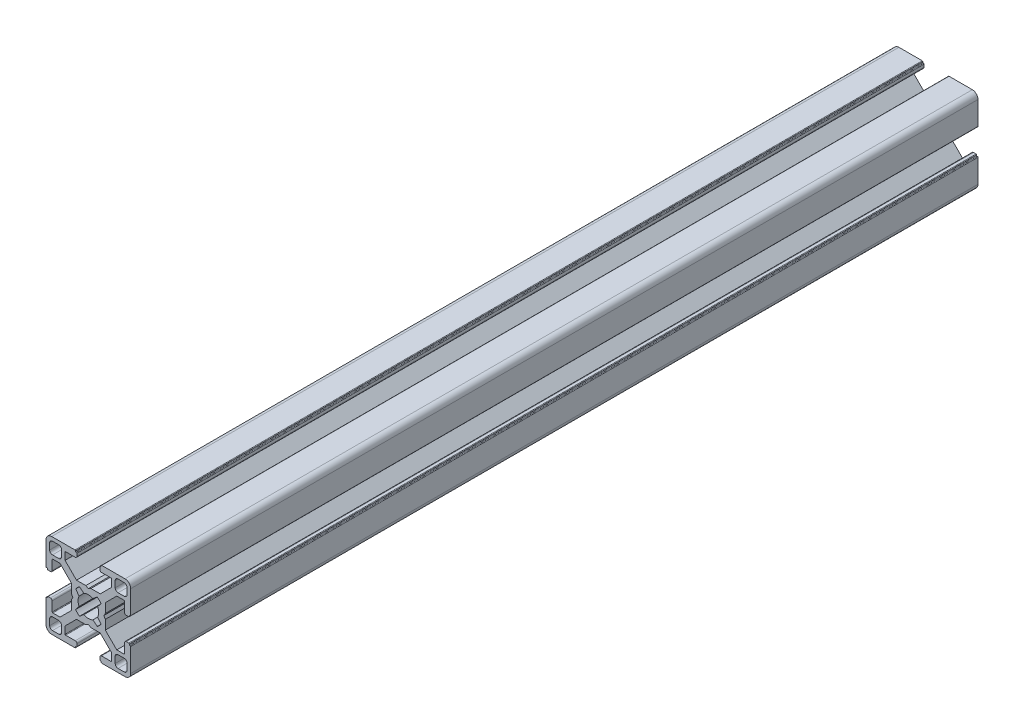
from build123d import *

# Parameters (mm, degrees)
BASE_EXTRUDE_DEPTH = 300


with BuildPart() as part:
    # Sketch1 → Base-Extrude (new body)
    with BuildSketch(Plane.XY):
        with BuildLine():
            Line((6.00446543, 0.899999619), (5.484852164, 0))
            Line((5.484852164, 0), (6.00446543, -0.899999619))
            Line((6.00446543, -0.899999619), (6.00446543, -4.204465866))
            Line((6.00446543, -4.204465866), (10.049999564, -8.25))
            Line((10.049999564, -8.25), (12.59999928, -8.25))
            ThreePointArc((12.59999928, -8.25), (12.741420837, -8.191421273), (12.799999564, -8.049999716))
            Line((12.799999564, -8.049999716), (12.799999564, -4.649999613))
            ThreePointArc((12.799999564, -4.649999613), (12.975735606, -4.225735278), (13.39999994, -4.049999237))
            Line((13.39999994, -4.049999237), (14.300000043, -4.049999237))
            ThreePointArc((14.300000043, -4.049999237), (14.4414216, -4.108577964), (14.500000327, -4.249999521))
            Line((14.500000327, -4.249999521), (14.500000327, -4.349998953))
            ThreePointArc((14.500000327, -4.349998953), (14.558579054, -4.49142051), (14.700000611, -4.549999237))
            Line((14.700000611, -4.549999237), (14.799999716, -4.549999237))
            ThreePointArc((14.799999716, -4.549999237), (14.941421273, -4.608577964), (15, -4.749999521))
            Line((15, -4.749999521), (15, -13.000000346))
            ThreePointArc((15, -13.000000346), (14.414213664, -14.414213664), (13.000000346, -15))
            Line((13.000000346, -15), (4.749999945, -15))
            ThreePointArc((4.749999945, -15), (4.60857832, -14.941421245), (4.549999564, -14.799999619))
            Line((4.549999564, -14.799999619), (4.549999564, -14.69999942))
            ThreePointArc((4.549999564, -14.69999942), (4.49142109, -14.558578474), (4.350000144, -14.5))
            Line((4.350000144, -14.5), (4.250000374, -14.5))
            ThreePointArc((4.250000374, -14.5), (4.108578753, -14.441421247), (4.05, -14.299999626))
            Line((4.05, -14.299999626), (4.05, -13.399999434))
            ThreePointArc((4.05, -13.399999434), (4.225735989, -12.975735226), (4.650000197, -12.799999237))
            Line((4.650000197, -12.799999237), (8.049999924, -12.799999237))
            ThreePointArc((8.049999924, -12.799999237), (8.191421565, -12.741420475), (8.250000327, -12.599998834))
            Line((8.250000327, -12.599998834), (8.250000327, -10.049999237))
            Line((8.250000327, -10.049999237), (4.204466193, -6))
            Line((4.204466193, -6), (0.899999946, -6))
            Line((0.899999946, -6), (0, -5.484851837))
            Line((0, -5.484851837), (-0.899999946, -6))
            Line((-0.899999946, -6), (-4.204466193, -6))
            Line((-4.204466193, -6), (-8.250000327, -10.049999237))
            Line((-8.250000327, -10.049999237), (-8.250000327, -12.599998834))
            ThreePointArc((-8.250000327, -12.599998834), (-8.191421565, -12.741420475), (-8.049999924, -12.799999237))
            Line((-8.049999924, -12.799999237), (-4.650000197, -12.799999237))
            ThreePointArc((-4.650000197, -12.799999237), (-4.225735989, -12.975735226), (-4.05, -13.399999434))
            Line((-4.05, -13.399999434), (-4.05, -14.299999626))
            ThreePointArc((-4.05, -14.299999626), (-4.108578753, -14.441421247), (-4.250000374, -14.5))
            Line((-4.250000374, -14.5), (-4.350000144, -14.5))
            ThreePointArc((-4.350000144, -14.5), (-4.49142109, -14.558578474), (-4.549999564, -14.69999942))
            Line((-4.549999564, -14.69999942), (-4.549999564, -14.799999619))
            ThreePointArc((-4.549999564, -14.799999619), (-4.60857832, -14.941421245), (-4.749999945, -15))
            Line((-4.749999945, -15), (-13.000000346, -15))
            ThreePointArc((-13.000000346, -15), (-14.414213664, -14.414213664), (-15, -13.000000346))
            Line((-15, -13.000000346), (-15, -4.749999521))
            ThreePointArc((-15, -4.749999521), (-14.941421273, -4.608577964), (-14.799999716, -4.549999237))
            Line((-14.799999716, -4.549999237), (-14.700000611, -4.549999237))
            ThreePointArc((-14.700000611, -4.549999237), (-14.558579054, -4.49142051), (-14.500000327, -4.349998953))
            Line((-14.500000327, -4.349998953), (-14.500000327, -4.249999521))
            ThreePointArc((-14.500000327, -4.249999521), (-14.4414216, -4.108577964), (-14.300000043, -4.049999237))
            Line((-14.300000043, -4.049999237), (-13.39999994, -4.049999237))
            ThreePointArc((-13.39999994, -4.049999237), (-12.975735606, -4.225735278), (-12.799999564, -4.649999613))
            Line((-12.799999564, -4.649999613), (-12.799999564, -8.049999716))
            ThreePointArc((-12.799999564, -8.049999716), (-12.741420837, -8.191421273), (-12.59999928, -8.25))
            Line((-12.59999928, -8.25), (-10.049999564, -8.25))
            Line((-10.049999564, -8.25), (-6.00446543, -4.204465866))
            Line((-6.00446543, -4.204465866), (-6.00446543, -0.899999619))
            Line((-6.00446543, -0.899999619), (-5.484852164, 0))
            Line((-5.484852164, 0), (-6.00446543, 0.899999619))
            Line((-6.00446543, 0.899999619), (-6.00446543, 4.204465866))
            Line((-6.00446543, 4.204465866), (-10.049999564, 8.25))
            Line((-10.049999564, 8.25), (-12.59999928, 8.25))
            ThreePointArc((-12.59999928, 8.25), (-12.741420837, 8.191421273), (-12.799999564, 8.049999716))
            Line((-12.799999564, 8.049999716), (-12.799999564, 4.649999613))
            ThreePointArc((-12.799999564, 4.649999613), (-12.975735606, 4.225735278), (-13.39999994, 4.049999237))
            Line((-13.39999994, 4.049999237), (-14.300000043, 4.049999237))
            ThreePointArc((-14.300000043, 4.049999237), (-14.4414216, 4.108577964), (-14.500000327, 4.249999521))
            Line((-14.500000327, 4.249999521), (-14.500000327, 4.349998953))
            ThreePointArc((-14.500000327, 4.349998953), (-14.558579054, 4.49142051), (-14.700000611, 4.549999237))
            Line((-14.700000611, 4.549999237), (-14.799999716, 4.549999237))
            ThreePointArc((-14.799999716, 4.549999237), (-14.941421273, 4.608577964), (-15, 4.749999521))
            Line((-15, 4.749999521), (-15, 13.000000346))
            ThreePointArc((-15, 13.000000346), (-14.414213664, 14.414213664), (-13.000000346, 15))
            Line((-13.000000346, 15), (-4.749999945, 15))
            ThreePointArc((-4.749999945, 15), (-4.60857832, 14.941421245), (-4.549999564, 14.799999619))
            Line((-4.549999564, 14.799999619), (-4.549999564, 14.69999942))
            ThreePointArc((-4.549999564, 14.69999942), (-4.49142109, 14.558578474), (-4.350000144, 14.5))
            Line((-4.350000144, 14.5), (-4.250000374, 14.5))
            ThreePointArc((-4.250000374, 14.5), (-4.108578753, 14.441421247), (-4.05, 14.299999626))
            Line((-4.05, 14.299999626), (-4.05, 13.399999434))
            ThreePointArc((-4.05, 13.399999434), (-4.225735989, 12.975735226), (-4.650000197, 12.799999237))
            Line((-4.650000197, 12.799999237), (-8.049999924, 12.799999237))
            ThreePointArc((-8.049999924, 12.799999237), (-8.191421565, 12.741420475), (-8.250000327, 12.599998834))
            Line((-8.250000327, 12.599998834), (-8.250000327, 10.049999237))
            Line((-8.250000327, 10.049999237), (-4.204466193, 6))
            Line((-4.204466193, 6), (-0.899999946, 6))
            Line((-0.899999946, 6), (0, 5.484851837))
            Line((0, 5.484851837), (0.899999946, 6))
            Line((0.899999946, 6), (4.204466193, 6))
            Line((4.204466193, 6), (8.250000327, 10.049999237))
            Line((8.250000327, 10.049999237), (8.250000327, 12.599998834))
            ThreePointArc((8.250000327, 12.599998834), (8.191421565, 12.741420475), (8.049999924, 12.799999237))
            Line((8.049999924, 12.799999237), (4.650000197, 12.799999237))
            ThreePointArc((4.650000197, 12.799999237), (4.225735989, 12.975735226), (4.05, 13.399999434))
            Line((4.05, 13.399999434), (4.05, 14.299999626))
            ThreePointArc((4.05, 14.299999626), (4.108578753, 14.441421247), (4.250000374, 14.5))
            Line((4.250000374, 14.5), (4.350000144, 14.5))
            ThreePointArc((4.350000144, 14.5), (4.49142109, 14.558578474), (4.549999564, 14.69999942))
            Line((4.549999564, 14.69999942), (4.549999564, 14.799999619))
            ThreePointArc((4.549999564, 14.799999619), (4.60857832, 14.941421245), (4.749999945, 15))
            Line((4.749999945, 15), (13.000000346, 15))
            ThreePointArc((13.000000346, 15), (14.414213664, 14.414213664), (15, 13.000000346))
            Line((15, 13.000000346), (15, 4.749999521))
            ThreePointArc((15, 4.749999521), (14.941421273, 4.608577964), (14.799999716, 4.549999237))
            Line((14.799999716, 4.549999237), (14.700000611, 4.549999237))
            ThreePointArc((14.700000611, 4.549999237), (14.558579054, 4.49142051), (14.500000327, 4.349998953))
            Line((14.500000327, 4.349998953), (14.500000327, 4.249999521))
            ThreePointArc((14.500000327, 4.249999521), (14.4414216, 4.108577964), (14.300000043, 4.049999237))
            Line((14.300000043, 4.049999237), (13.39999994, 4.049999237))
            ThreePointArc((13.39999994, 4.049999237), (12.975735606, 4.225735278), (12.799999564, 4.649999613))
            Line((12.799999564, 4.649999613), (12.799999564, 8.049999716))
            ThreePointArc((12.799999564, 8.049999716), (12.741420837, 8.191421273), (12.59999928, 8.25))
            Line((12.59999928, 8.25), (10.049999564, 8.25))
            Line((10.049999564, 8.25), (6.00446543, 4.204465866))
            Line((6.00446543, 4.204465866), (6.00446543, 0.899999619))
        make_face()
        with BuildLine():
            Line((13.70000109, 12.700000398), (13.70000109, 10.499999635))
            ThreePointArc((13.70000109, 10.499999635), (13.407107874, 9.792892851), (12.70000109, 9.499999635))
            Line((12.70000109, 9.499999635), (10.500000327, 9.499999635))
            ThreePointArc((10.500000327, 9.499999635), (9.792893543, 9.792892851), (9.500000327, 10.499999635))
            Line((9.500000327, 10.499999635), (9.500000327, 12.700000398))
            ThreePointArc((9.500000327, 12.700000398), (9.792893543, 13.407107182), (10.500000327, 13.700000398))
            Line((10.500000327, 13.700000398), (12.70000109, 13.700000398))
            ThreePointArc((12.70000109, 13.700000398), (13.407107874, 13.407107182), (13.70000109, 12.700000398))
        make_face(mode=Mode.SUBTRACT)
        with BuildLine():
            Line((3.135929412, 4.518400903), (1.600129524, 3.280561767))
            ThreePointArc((1.600129524, 3.280561767), (0, 3.65), (-1.600129524, 3.280561767))
            Line((-1.600129524, 3.280561767), (-3.135929412, 4.518400903))
            ThreePointArc((-3.135929412, 4.518400903), (-3.881002259, 3.897155561), (-4.505336892, 3.154669473))
            Line((-4.505336892, 3.154669473), (-3.280561732, 1.600129597))
            ThreePointArc((-3.280561732, 1.600129597), (-3.65, 0), (-3.280561732, -1.600129597))
            Line((-3.280561732, -1.600129597), (-4.505336892, -3.154669473))
            ThreePointArc((-4.505336892, -3.154669473), (-3.881002259, -3.897155561), (-3.135929412, -4.518400903))
            Line((-3.135929412, -4.518400903), (-1.600129524, -3.280561767))
            ThreePointArc((-1.600129524, -3.280561767), (0, -3.65), (1.600129524, -3.280561767))
            Line((1.600129524, -3.280561767), (3.135929412, -4.518400903))
            ThreePointArc((3.135929412, -4.518400903), (3.881002259, -3.897155561), (4.505336892, -3.154669473))
            Line((4.505336892, -3.154669473), (3.280561732, -1.600129597))
            ThreePointArc((3.280561732, -1.600129597), (3.65, 0), (3.280561732, 1.600129597))
            Line((3.280561732, 1.600129597), (4.505336892, 3.154669473))
            ThreePointArc((4.505336892, 3.154669473), (3.881002259, 3.897155561), (3.135929412, 4.518400903))
        make_face(mode=Mode.SUBTRACT)
        with BuildLine():
            Line((-13.70000109, -12.700000398), (-13.70000109, -10.499999635))
            ThreePointArc((-13.70000109, -10.499999635), (-13.407107874, -9.792892851), (-12.70000109, -9.499999635))
            Line((-12.70000109, -9.499999635), (-10.500000327, -9.499999635))
            ThreePointArc((-10.500000327, -9.499999635), (-9.792893543, -9.792892851), (-9.500000327, -10.499999635))
            Line((-9.500000327, -10.499999635), (-9.500000327, -12.700000398))
            ThreePointArc((-9.500000327, -12.700000398), (-9.792893543, -13.407107182), (-10.500000327, -13.700000398))
            Line((-10.500000327, -13.700000398), (-12.70000109, -13.700000398))
            ThreePointArc((-12.70000109, -13.700000398), (-13.407107874, -13.407107182), (-13.70000109, -12.700000398))
        make_face(mode=Mode.SUBTRACT)
        with BuildLine():
            Line((10.500000327, -13.700000398), (12.70000109, -13.700000398))
            ThreePointArc((12.70000109, -13.700000398), (13.407107874, -13.407107182), (13.70000109, -12.700000398))
            Line((13.70000109, -12.700000398), (13.70000109, -10.499999635))
            ThreePointArc((13.70000109, -10.499999635), (13.407107874, -9.792892851), (12.70000109, -9.499999635))
            Line((12.70000109, -9.499999635), (10.500000327, -9.499999635))
            ThreePointArc((10.500000327, -9.499999635), (9.792893543, -9.792892851), (9.500000327, -10.499999635))
            Line((9.500000327, -10.499999635), (9.500000327, -12.700000398))
            ThreePointArc((9.500000327, -12.700000398), (9.792893543, -13.407107182), (10.500000327, -13.700000398))
        make_face(mode=Mode.SUBTRACT)
        with BuildLine():
            Line((-10.500000327, 13.700000398), (-12.70000109, 13.700000398))
            ThreePointArc((-12.70000109, 13.700000398), (-13.407107874, 13.407107182), (-13.70000109, 12.700000398))
            Line((-13.70000109, 12.700000398), (-13.70000109, 10.499999635))
            ThreePointArc((-13.70000109, 10.499999635), (-13.407107874, 9.792892851), (-12.70000109, 9.499999635))
            Line((-12.70000109, 9.499999635), (-10.500000327, 9.499999635))
            ThreePointArc((-10.500000327, 9.499999635), (-9.792893543, 9.792892851), (-9.500000327, 10.499999635))
            Line((-9.500000327, 10.499999635), (-9.500000327, 12.700000398))
            ThreePointArc((-9.500000327, 12.700000398), (-9.792893543, 13.407107182), (-10.500000327, 13.700000398))
        make_face(mode=Mode.SUBTRACT)
    extrude(amount=-BASE_EXTRUDE_DEPTH)


solid = part.part
